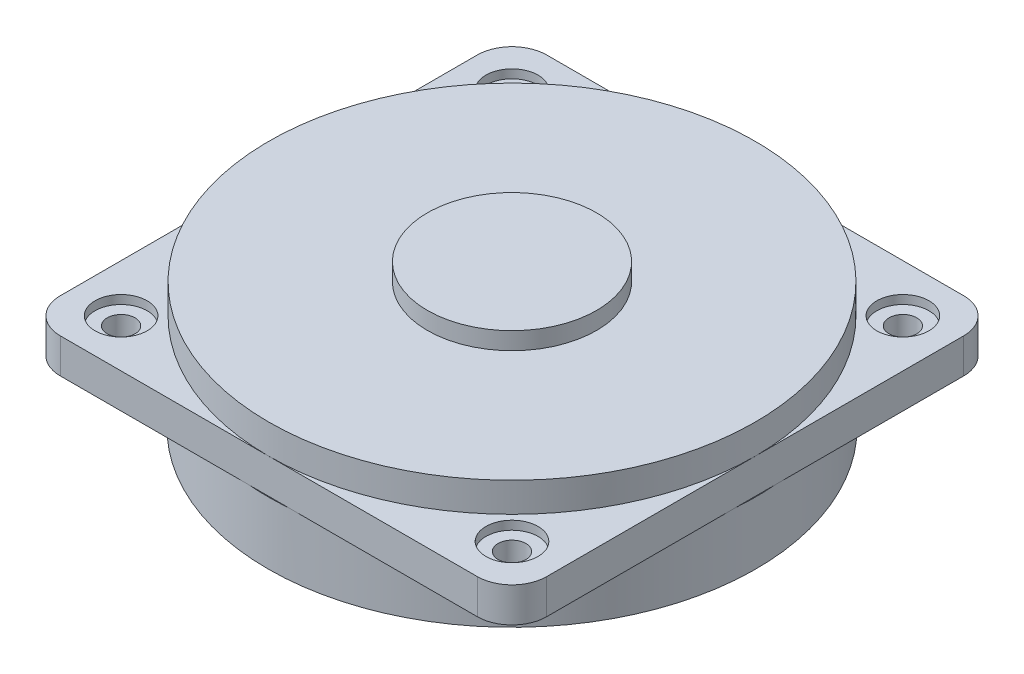
from build123d import *

# Parameters (mm, degrees)
SKETCH1_W           = 28
SKETCH1_H           = 28
BOSS_EXTRUDE1_DEPTH = 2
SKETCH2_R           = 14.045
SKETCH2_R_2         = 12.545
BOSS_EXTRUDE2_DEPTH = 3.6
SKETCH3_R           = 14
BOSS_EXTRUDE3_DEPTH = 1.7
SKETCH4_R           = 4.869542796
BOSS_EXTRUDE4_DEPTH = 1
SKETCH5_R           = 7.569237382
BOSS_EXTRUDE5_DEPTH = 3.6
SKETCH6_R           = 1.5
CUT_EXTRUDE1_DEPTH  = 0.5
SKETCH7_R           = 0.8
CUT_EXTRUDE2_DEPTH  = 6.1
FILLET1_R           = 2


with BuildPart() as part:
    # Sketch1 → Boss-Extrude1 (new body)
    with BuildSketch(Plane(origin=(0, 0, 0), x_dir=(1, 0, 0), z_dir=(0, 1, 0))):
        Rectangle(SKETCH1_W, SKETCH1_H)
    extrude(amount=BOSS_EXTRUDE1_DEPTH)

    # Sketch2 → Boss-Extrude2 (add)
    with BuildSketch(Plane.XZ):
        Circle(SKETCH2_R)
        Circle(SKETCH2_R_2, mode=Mode.SUBTRACT)
    extrude(amount=BOSS_EXTRUDE2_DEPTH)

    # Sketch3 → Boss-Extrude3 (add)
    with BuildSketch(Plane(origin=(0, 2, 0), x_dir=(1, 0, 0), z_dir=(0, 1, 0))):
        Circle(SKETCH3_R)
    extrude(amount=BOSS_EXTRUDE3_DEPTH)

    # Sketch4 → Boss-Extrude4 (add)
    with BuildSketch(Plane(origin=(0, 3.7, 0), x_dir=(1, 0, 0), z_dir=(0, 1, 0))):
        Circle(SKETCH4_R)
    extrude(amount=BOSS_EXTRUDE4_DEPTH)

    # Sketch5 → Boss-Extrude5 (add)
    with BuildSketch(Plane.XZ):
        Circle(SKETCH5_R)
    extrude(amount=BOSS_EXTRUDE5_DEPTH)

    # Sketch6 → Cut-Extrude1 (cut)
    with BuildSketch(Plane(origin=(0, 2, 0), x_dir=(1, 0, 0), z_dir=(0, 1, 0))):
        with Locations((11.25, 11.25)):
            Circle(SKETCH6_R)
        with Locations((-11.25, 11.25)):
            Circle(SKETCH6_R)
        with Locations((-11.25, -11.25)):
            Circle(SKETCH6_R)
        with Locations((11.25, -11.25)):
            Circle(SKETCH6_R)
    extrude(amount=-CUT_EXTRUDE1_DEPTH, mode=Mode.SUBTRACT)

    # Sketch7 → Cut-Extrude2 (cut, through all)
    with BuildSketch(Plane(origin=(0, 1.5, 0), x_dir=(1, 0, 0), z_dir=(0, 1, 0))):
        with Locations((-11.25, 11.25)):
            Circle(SKETCH7_R)
        with Locations((11.25, 11.25)):
            Circle(SKETCH7_R)
        with Locations((11.25, -11.25)):
            Circle(SKETCH7_R)
        with Locations((-11.25, -11.25)):
            Circle(SKETCH7_R)
    extrude(amount=-CUT_EXTRUDE2_DEPTH, mode=Mode.SUBTRACT)

    # Fillet1
    fillet1_edges = [part.edges().sort_by_distance(p)[0] for p in [
        (14, 1, 14),
        (-14, 1, 14),
        (-14, 1, -14),
        (14, 1, -14),
    ]]
    fillet(fillet1_edges, radius=FILLET1_R)


solid = part.part
